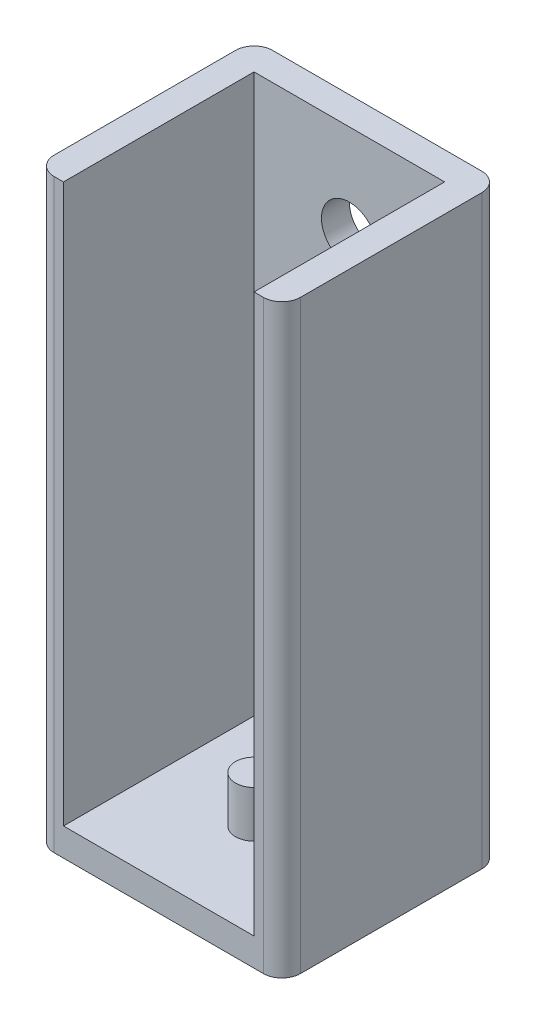
from build123d import *

# Parameters (mm, degrees)
BOSS_EXTRUDE1_DEPTH = 60
SKETCH2_W           = 20.5
SKETCH2_H           = 20.5
BOSS_EXTRUDE2_DEPTH = 3
SKETCH3_R           = 2
BOSS_EXTRUDE3_DEPTH = 5
SKETCH4_R           = 3
CUT_EXTRUDE1_DEPTH  = 23.5


with BuildPart() as part:
    # Sketch1 → Boss-Extrude1 (new body)
    with BuildSketch(Plane(origin=(0, 0, 0), x_dir=(1, 0, 0), z_dir=(0, 1, 0))):
        with BuildLine():
            Line((-13.25, 11.25), (-13.25, -8.25))
            ThreePointArc((-13.25, -8.25), (-12.664213562, -9.664213562), (-11.25, -10.25))
            Line((-11.25, -10.25), (-10.25, -10.25))
            Line((-10.25, -10.25), (-10.25, 10.25))
            Line((-10.25, 10.25), (10.25, 10.25))
            Line((10.25, 10.25), (10.25, -10.25))
            Line((10.25, -10.25), (11.25, -10.25))
            ThreePointArc((11.25, -10.25), (12.664213562, -9.664213562), (13.25, -8.25))
            Line((13.25, -8.25), (13.25, 11.25))
            ThreePointArc((13.25, 11.25), (12.664213562, 12.664213562), (11.25, 13.25))
            Line((11.25, 13.25), (-11.25, 13.25))
            ThreePointArc((-11.25, 13.25), (-12.664213562, 12.664213562), (-13.25, 11.25))
        make_face()
    extrude(amount=BOSS_EXTRUDE1_DEPTH)

    # Sketch2 → Boss-Extrude2 (add)
    with BuildSketch(Plane.XZ):
        with BuildLine():
            ThreePointArc((-11.25, 10.25), (-12.664213562, 9.664213562), (-13.25, 8.25))
            Line((-13.25, 8.25), (-13.25, -11.25))
            ThreePointArc((-13.25, -11.25), (-12.664213562, -12.664213562), (-11.25, -13.25))
            Line((-11.25, -13.25), (11.25, -13.25))
            ThreePointArc((11.25, -13.25), (12.664213562, -12.664213562), (13.25, -11.25))
            Line((13.25, -11.25), (13.25, 8.25))
            ThreePointArc((13.25, 8.25), (12.664213562, 9.664213562), (11.25, 10.25))
            Line((11.25, 10.25), (10.25, 10.25))
            Line((10.25, 10.25), (10.25, -10.25))
            Line((10.25, -10.25), (-10.25, -10.25))
            Line((-10.25, -10.25), (-10.25, 10.25))
            Line((-10.25, 10.25), (-11.25, 10.25))
        make_face()
        Rectangle(SKETCH2_W, SKETCH2_H)
    extrude(amount=BOSS_EXTRUDE2_DEPTH)

    # Sketch3 → Boss-Extrude3 (add)
    with BuildSketch(Plane(origin=(0, 0, 0), x_dir=(1, 0, 0), z_dir=(0, 1, 0))):
        Circle(SKETCH3_R)
    extrude(amount=BOSS_EXTRUDE3_DEPTH)

    # Sketch4 → Cut-Extrude1 (cut)
    with BuildSketch(Plane(origin=(0, 0, -13.25), x_dir=(-1, 0, 0), z_dir=(0, 0, -1))):
        with Locations((0, 50)):
            Circle(SKETCH4_R)
        with Locations((0, 17)):
            Circle(SKETCH4_R)
    extrude(amount=-CUT_EXTRUDE1_DEPTH, mode=Mode.SUBTRACT)


solid = part.part
